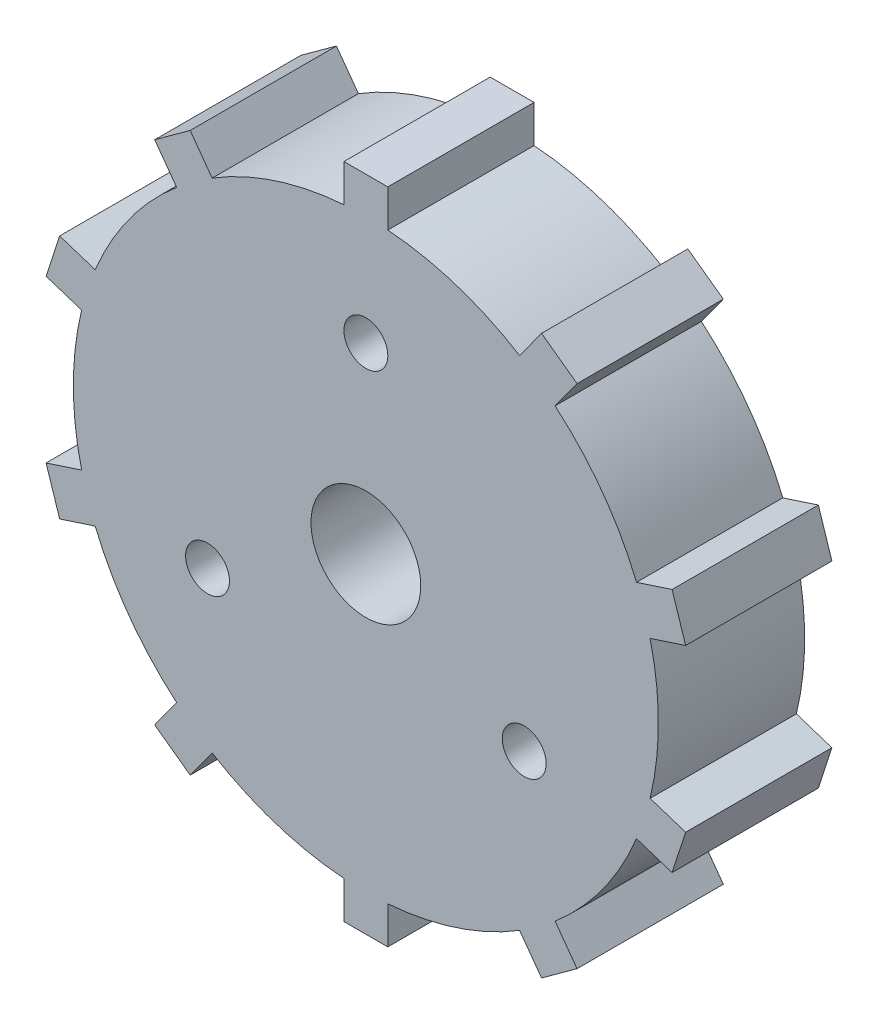
from build123d import *

# Parameters (mm, degrees)
SKETCH_1_R          = 1.5
EXTRUDE_1_DEPTH     = 10
SKETCH_2_R          = 3.75
CUT_EXTRUDE_1_DEPTH = 10


with BuildPart() as part:
    # 草图1 → 凸台-拉伸1 (new body)
    with BuildSketch(Plane.XY):
        with BuildLine():
            Line((1.5, 19.943670675), (1.5, 22.5))
            Line((1.5, 22.5), (-1.5, 22.5))
            Line((-1.5, 22.5), (-1.5, 19.943670675))
            ThreePointArc((-1.5, 19.943670675), (-6.180339887, 19.021130326), (-10.509070008, 17.016446385))
            Line((-10.509070008, 17.016446385), (-12.011642685, 19.084560252))
            Line((-12.011642685, 19.084560252), (-14.438693668, 17.321204495))
            Line((-14.438693668, 17.321204495), (-12.936120991, 15.253090628))
            ThreePointArc((-12.936120991, 15.253090628), (-16.180339887, 11.755705046), (-18.504032463, 7.589517943))
            Line((-18.504032463, 7.589517943), (-20.935246125, 8.379467148))
            Line((-20.935246125, 8.379467148), (-21.862297108, 5.526297599))
            Line((-21.862297108, 5.526297599), (-19.431083446, 4.736348394))
            ThreePointArc((-19.431083446, 4.736348394), (-20, 0), (-19.431083446, -4.736348394))
            Line((-19.431083446, -4.736348394), (-21.862297108, -5.526297599))
            Line((-21.862297108, -5.526297599), (-20.935246125, -8.379467148))
            Line((-20.935246125, -8.379467148), (-18.504032463, -7.589517943))
            ThreePointArc((-18.504032463, -7.589517943), (-16.180339887, -11.755705046), (-12.936120991, -15.253090628))
            Line((-12.936120991, -15.253090628), (-14.438693668, -17.321204495))
            Line((-14.438693668, -17.321204495), (-12.011642685, -19.084560252))
            Line((-12.011642685, -19.084560252), (-10.509070008, -17.016446385))
            ThreePointArc((-10.509070008, -17.016446385), (-6.180339887, -19.021130326), (-1.5, -19.943670675))
            Line((-1.5, -19.943670675), (-1.5, -22.5))
            Line((-1.5, -22.5), (1.5, -22.5))
            Line((1.5, -22.5), (1.5, -19.943670675))
            ThreePointArc((1.5, -19.943670675), (6.180339887, -19.021130326), (10.509070008, -17.016446385))
            Line((10.509070008, -17.016446385), (12.011642685, -19.084560252))
            Line((12.011642685, -19.084560252), (14.438693668, -17.321204495))
            Line((14.438693668, -17.321204495), (12.936120991, -15.253090628))
            ThreePointArc((12.936120991, -15.253090628), (16.180339887, -11.755705046), (18.504032463, -7.589517943))
            Line((18.504032463, -7.589517943), (20.935246125, -8.379467148))
            Line((20.935246125, -8.379467148), (21.862297108, -5.526297599))
            Line((21.862297108, -5.526297599), (19.431083446, -4.736348394))
            ThreePointArc((19.431083446, -4.736348394), (20, 0), (19.431083446, 4.736348394))
            Line((19.431083446, 4.736348394), (21.862297108, 5.526297599))
            Line((21.862297108, 5.526297599), (20.935246125, 8.379467148))
            Line((20.935246125, 8.379467148), (18.504032463, 7.589517943))
            ThreePointArc((18.504032463, 7.589517943), (16.180339887, 11.755705046), (12.936120991, 15.253090628))
            Line((12.936120991, 15.253090628), (14.438693668, 17.321204495))
            Line((14.438693668, 17.321204495), (12.011642685, 19.084560252))
            Line((12.011642685, 19.084560252), (10.509070008, 17.016446385))
            ThreePointArc((10.509070008, 17.016446385), (6.180339887, 19.021130326), (1.5, 19.943670675))
        make_face()
        with Locations((0, 12.5)):
            Circle(SKETCH_1_R, mode=Mode.SUBTRACT)
        with Locations((10.825317547, -6.25)):
            Circle(SKETCH_1_R, mode=Mode.SUBTRACT)
        with Locations((-10.825317547, -6.25)):
            Circle(SKETCH_1_R, mode=Mode.SUBTRACT)
    extrude(amount=EXTRUDE_1_DEPTH)

    # 草图2 → 切除-拉伸1 (cut)
    with BuildSketch(Plane.XY):
        Circle(SKETCH_2_R)
    extrude(amount=CUT_EXTRUDE_1_DEPTH, mode=Mode.SUBTRACT)


solid = part.part
